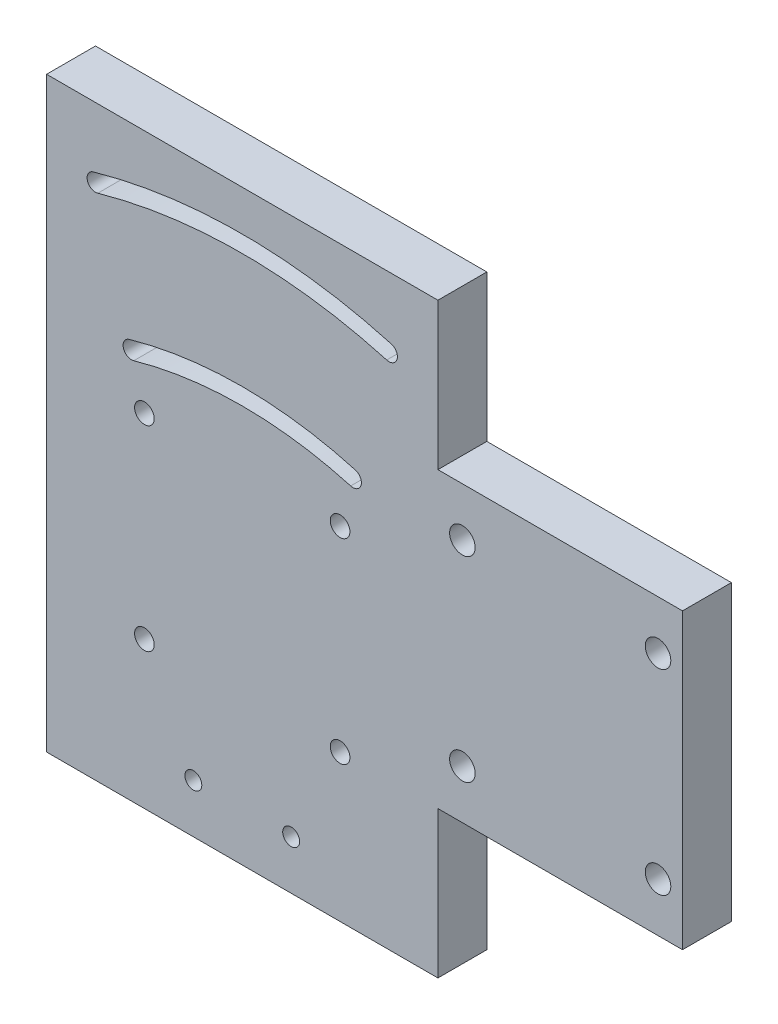
from build123d import *

# Parameters (mm, degrees)
SKETCH1_W            = 63.5
SKETCH1_H            = 76.2
EXTRUDE1_DEPTH       = 12.7
SKETCH4_R            = 3.3147
SKETCH4_R_2          = 2.5527
CUT_EXTRUDE2_DEPTH   = 12.7
LPATTERN2_COUNT      = 2
LPATTERN2_PITCH      = 50.8
LPATTERN2_COUNT_DIR2 = 2
LPATTERN2_PITCH_DIR2 = 50.8
SKETCH5_R            = 2.1971
CUT_EXTRUDE4_DEPTH   = 13.7


with BuildPart() as part:
    # Sketch1 → Extrude1 (new body)
    with BuildSketch(Plane.XY):
        Polygon((0, 152.4), (0, 0), (101.6, 0), (101.6, 38.1), (101.6, 114.3), (101.6, 152.4), align=None)
        with Locations((133.35, 76.2)):
            Rectangle(SKETCH1_W, SKETCH1_H)
    extrude(amount=EXTRUDE1_DEPTH)

    # Sketch4 → Cut-Extrude2 (cut)
    with BuildSketch(Plane.XY.offset(12.7)):
        with Locations((158.75, 101.6)):
            Circle(SKETCH4_R)
        with Locations((76.2, 88.9)):
            Circle(SKETCH4_R_2)
    cut_extrude2 = extrude(amount=-CUT_EXTRUDE2_DEPTH, mode=Mode.SUBTRACT)

    # LPattern2: Cut-Extrude2 2 × 2
    with Locations(*[(-i * LPATTERN2_PITCH, -j * LPATTERN2_PITCH_DIR2, 0) for i in range(LPATTERN2_COUNT) for j in range(LPATTERN2_COUNT_DIR2) if (i, j) != (0, 0)]):
        add(cut_extrude2, mode=Mode.SUBTRACT)

    # Sketch5 → Cut-Extrude4 (cut, through all)
    with BuildSketch(Plane.XY.offset(12.7)):
        with Locations((38.1, 12.7)):
            Circle(SKETCH5_R)
        with Locations((63.5, 12.7)):
            Circle(SKETCH5_R)
        with BuildLine():
            ThreePointArc((22.647563636, 99.312460558), (50.8, 103.2256), (78.952436364, 99.312460558))
            ThreePointArc((78.952436364, 99.312460558), (81.649774241, 100.818307527), (80.143927273, 103.515645405))
            ThreePointArc((80.143927273, 103.515645405), (50.8, 107.5944), (21.456072727, 103.515645405))
            ThreePointArc((21.456072727, 103.515645405), (19.950225759, 100.818307527), (22.647563636, 99.312460558))
        make_face()
        with BuildLine():
            ThreePointArc((13.295745455, 132.302574179), (50.8, 137.5156), (88.304254545, 132.302574179))
            ThreePointArc((88.304254545, 132.302574179), (91.001592423, 133.808421148), (89.495745455, 136.505759025))
            ThreePointArc((89.495745455, 136.505759025), (50.8, 141.8844), (12.104254545, 136.505759025))
            ThreePointArc((12.104254545, 136.505759025), (10.598407577, 133.808421148), (13.295745455, 132.302574179))
        make_face()
    extrude(amount=-CUT_EXTRUDE4_DEPTH, mode=Mode.SUBTRACT)


solid = part.part
